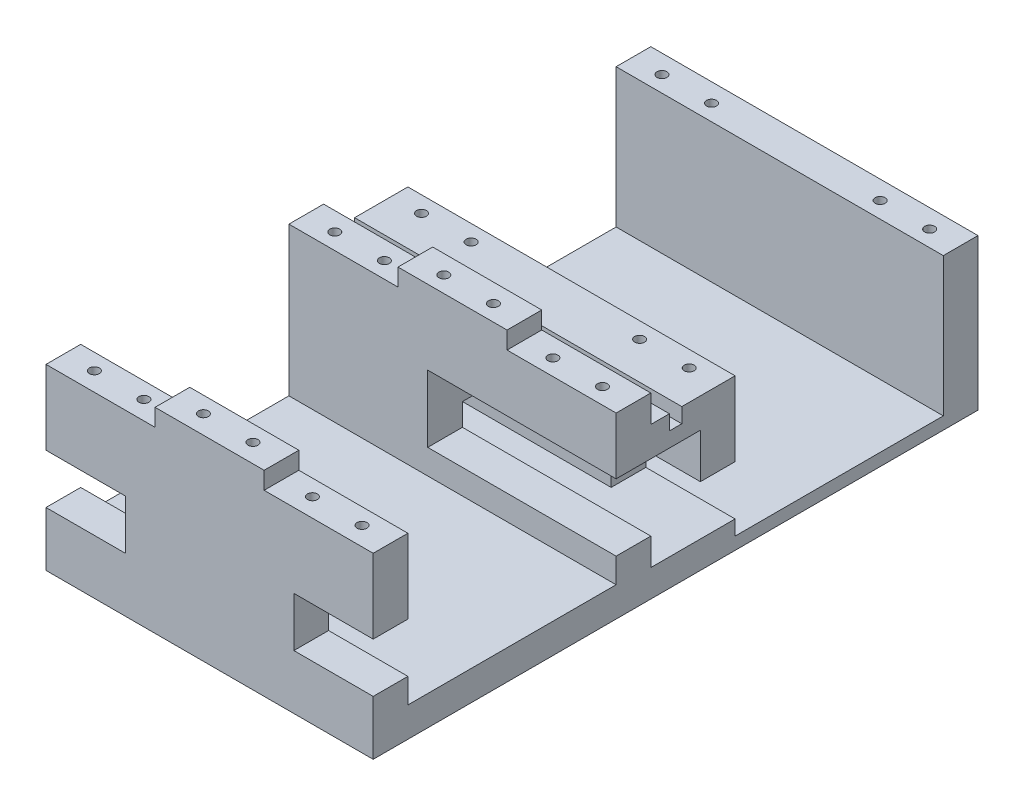
from build123d import *

# Parameters (mm, degrees)
SKETCH1_W            = 66
SKETCH1_H            = 56
BOSS_EXTRUDE1_DEPTH  = 6
SKETCH2_W            = 66
SKETCH2_H            = 7
BOSS_EXTRUDE2_DEPTH  = 30
SKETCH4_W            = 22
SKETCH4_H            = 7
BOSS_EXTRUDE3_DEPTH  = 3.5
SKETCH6_R            = 1
CUT_EXTRUDE1_DEPTH   = 10
SKETCH15_W           = 66
SKETCH15_H           = 66
BOSS_EXTRUDE4_DEPTH  = 2.5
SKETCH16_W           = 66
SKETCH16_H           = 7
BOSS_EXTRUDE6_DEPTH  = 28
SKETCH17_R           = 1
CUT_EXTRUDE2_DEPTH   = 10
CUT_EXTRUDE3_REACH   = 9
SKETCH14_W           = 16
SKETCH14_H           = 10
CUT_EXTRUDE4_REACH   = 75
SKETCH19_W           = 18
SKETCH19_H           = 10
SKETCH24_W           = 66
SKETCH24_H           = 15
BOSS_EXTRUDE9_DEPTH  = 10
SKETCH27_W           = 38
SKETCH27_H           = 13.5
CUT_EXTRUDE9_DEPTH   = 17
SKETCH26_W           = 66
SKETCH26_H           = 3
BOSS_EXTRUDE10_DEPTH = 10
SKETCH28_W           = 66
SKETCH28_H           = 2.5
CUT_EXTRUDE10_DEPTH  = 3


with BuildPart() as part:
    # Sketch1 → Boss-Extrude1 (new body)
    with BuildSketch(Plane(origin=(0, 0, 0), x_dir=(1, 0, 0), z_dir=(0, 1, 0))):
        with Locations((33, 28)):
            Rectangle(SKETCH1_W, SKETCH1_H)
    boss_extrude1 = extrude(amount=BOSS_EXTRUDE1_DEPTH)

    # Sketch2 → Boss-Extrude2 (add)
    with BuildSketch(Plane(origin=(0, 6, 0), x_dir=(1, 0, 0), z_dir=(0, 1, 0))):
        with Locations((33, 52.5)):
            Rectangle(SKETCH2_W, SKETCH2_H)
    boss_extrude2 = extrude(amount=BOSS_EXTRUDE2_DEPTH)

    # Sketch4 → Boss-Extrude3 (add)
    with BuildSketch(Plane(origin=(0, 36, 0), x_dir=(1, 0, 0), z_dir=(0, 1, 0))):
        with Locations((33, 52.5)):
            Rectangle(SKETCH4_W, SKETCH4_H)
    boss_extrude3 = extrude(amount=BOSS_EXTRUDE3_DEPTH)

    # Sketch6 → Cut-Extrude1 (cut, symmetric)
    with BuildSketch(Plane(origin=(0, 36, 0), x_dir=(1, 0, 0), z_dir=(0, 1, 0))):
        with Locations((6, 52.25)):
            Circle(SKETCH6_R)
        with Locations((16, 52.25)):
            Circle(SKETCH6_R)
        with Locations((38, 52.25)):
            Circle(SKETCH6_R)
        with Locations((28, 52.25)):
            Circle(SKETCH6_R)
        with Locations((60, 52.25)):
            Circle(SKETCH6_R)
        with Locations((50, 52.25)):
            Circle(SKETCH6_R)
    cut_extrude1 = extrude(amount=CUT_EXTRUDE1_DEPTH, both=True, mode=Mode.SUBTRACT)

    # Mirror1: Boss-Extrude1, Boss-Extrude2, Boss-Extrude3, Cut-Extrude1 across plane
    add(boss_extrude1.mirror(Plane.XY.offset(-28)))
    add(boss_extrude2.mirror(Plane.XY.offset(-28)))
    add(boss_extrude3.mirror(Plane.XY.offset(-28)))
    add(cut_extrude1.mirror(Plane.XY.offset(-28)), mode=Mode.SUBTRACT)

    # Sketch15 → Boss-Extrude4 (add)
    with BuildSketch(Plane(origin=(0, 0, 0), x_dir=(1, 0, 0), z_dir=(0, 1, 0))):
        with Locations((33, 89)):
            Rectangle(SKETCH15_W, SKETCH15_H)
    extrude(amount=BOSS_EXTRUDE4_DEPTH)

    # Sketch16 → Boss-Extrude6 (add)
    with BuildSketch(Plane(origin=(0, 2.5, 0), x_dir=(1, 0, 0), z_dir=(0, 1, 0))):
        with Locations((33, 69.5)):
            Rectangle(SKETCH16_W, SKETCH16_H)
    boss_extrude6 = extrude(amount=BOSS_EXTRUDE6_DEPTH)

    # Sketch17 → Cut-Extrude2 (cut)
    with BuildSketch(Plane(origin=(0, 30.5, 0), x_dir=(1, 0, 0), z_dir=(0, 1, 0))):
        with Locations((6, 69.75)):
            Circle(SKETCH17_R)
        with Locations((16, 69.75)):
            Circle(SKETCH17_R)
        with Locations((50, 69.75)):
            Circle(SKETCH17_R)
        with Locations((60, 69.75)):
            Circle(SKETCH17_R)
    cut_extrude2 = extrude(amount=-CUT_EXTRUDE2_DEPTH, mode=Mode.SUBTRACT)

    # Mirror2: Boss-Extrude6, Cut-Extrude2 across plane
    add(boss_extrude6.mirror(Plane(origin=(0, 0, -94), x_dir=(1, 0, 0), z_dir=(0, 0, -1))))
    add(cut_extrude2.mirror(Plane(origin=(0, 0, -94), x_dir=(1, 0, 0), z_dir=(0, 0, -1))), mode=Mode.SUBTRACT)

    # Sketch14 → Cut-Extrude3 (cut, up to next)
    with BuildSketch(Plane(origin=(0, 0, -7), x_dir=(-1, 0, 0), z_dir=(0, 0, -1)), mode=Mode.PRIVATE) as cut_extrude3_sk1:
        with Locations((-8, 16)):
            Rectangle(SKETCH14_W, SKETCH14_H)
    cut_extrude3_tool1 = extrude(cut_extrude3_sk1.sketch, amount=-CUT_EXTRUDE3_REACH, mode=Mode.PRIVATE) & part.part
    add(cut_extrude3_tool1.solids().sort_by_distance((8, 16, -7))[0], mode=Mode.SUBTRACT)
    # Sketch14 → Cut-Extrude3 (cut, up to next)
    with BuildSketch(Plane(origin=(0, 0, -7), x_dir=(-1, 0, 0), z_dir=(0, 0, -1)), mode=Mode.PRIVATE) as cut_extrude3_sk2:
        with Locations((-58, 16)):
            Rectangle(SKETCH14_W, SKETCH14_H)
    cut_extrude3_tool2 = extrude(cut_extrude3_sk2.sketch, amount=-CUT_EXTRUDE3_REACH, mode=Mode.PRIVATE) & part.part
    add(cut_extrude3_tool2.solids().sort_by_distance((58, 16, -7))[0], mode=Mode.SUBTRACT)

    # Sketch19 → Cut-Extrude4 (cut, up to next)
    with BuildSketch(Plane(origin=(0, 0, -73), x_dir=(-1, 0, 0), z_dir=(0, 0, -1)), mode=Mode.PRIVATE) as cut_extrude4_sk1:
        with Locations((-9, 10.5)):
            Rectangle(SKETCH19_W, SKETCH19_H)
    cut_extrude4_tool1 = extrude(cut_extrude4_sk1.sketch, amount=-CUT_EXTRUDE4_REACH, mode=Mode.PRIVATE) & part.part
    add(cut_extrude4_tool1.solids().sort_by_distance((9, 10.5, -73))[0], mode=Mode.SUBTRACT)
    # Sketch19 → Cut-Extrude4 (cut, up to next)
    with BuildSketch(Plane(origin=(0, 0, -73), x_dir=(-1, 0, 0), z_dir=(0, 0, -1)), mode=Mode.PRIVATE) as cut_extrude4_sk2:
        with Locations((-57, 10.5)):
            Rectangle(SKETCH19_W, SKETCH19_H)
    cut_extrude4_tool2 = extrude(cut_extrude4_sk2.sketch, amount=-CUT_EXTRUDE4_REACH, mode=Mode.PRIVATE) & part.part
    add(cut_extrude4_tool2.solids().sort_by_distance((57, 10.5, -73))[0], mode=Mode.SUBTRACT)

    # Sketch24 → Boss-Extrude9 (add)
    with BuildSketch(Plane.XY.offset(-66)):
        with Locations((33, 23)):
            Rectangle(SKETCH24_W, SKETCH24_H)
    extrude(amount=BOSS_EXTRUDE9_DEPTH)

    # Sketch27 → Cut-Extrude9 (cut)
    with BuildSketch(Plane.XY.offset(-49)):
        with Locations((47, 17.75)):
            Rectangle(SKETCH27_W, SKETCH27_H)
    extrude(amount=-CUT_EXTRUDE9_DEPTH, mode=Mode.SUBTRACT)

    # Sketch26 → Boss-Extrude10 (add)
    with BuildSketch(Plane.XY.offset(-66)):
        with Locations((33, 4)):
            Rectangle(SKETCH26_W, SKETCH26_H)
    extrude(amount=BOSS_EXTRUDE10_DEPTH)

    # Sketch28 → Cut-Extrude10 (cut)
    with BuildSketch(Plane(origin=(0, 30.5, 0), x_dir=(1, 0, 0), z_dir=(0, 1, 0))):
        with Locations((33, 61)):
            Rectangle(SKETCH28_W, SKETCH28_H)
    extrude(amount=-CUT_EXTRUDE10_DEPTH, mode=Mode.SUBTRACT)


solid = part.part
